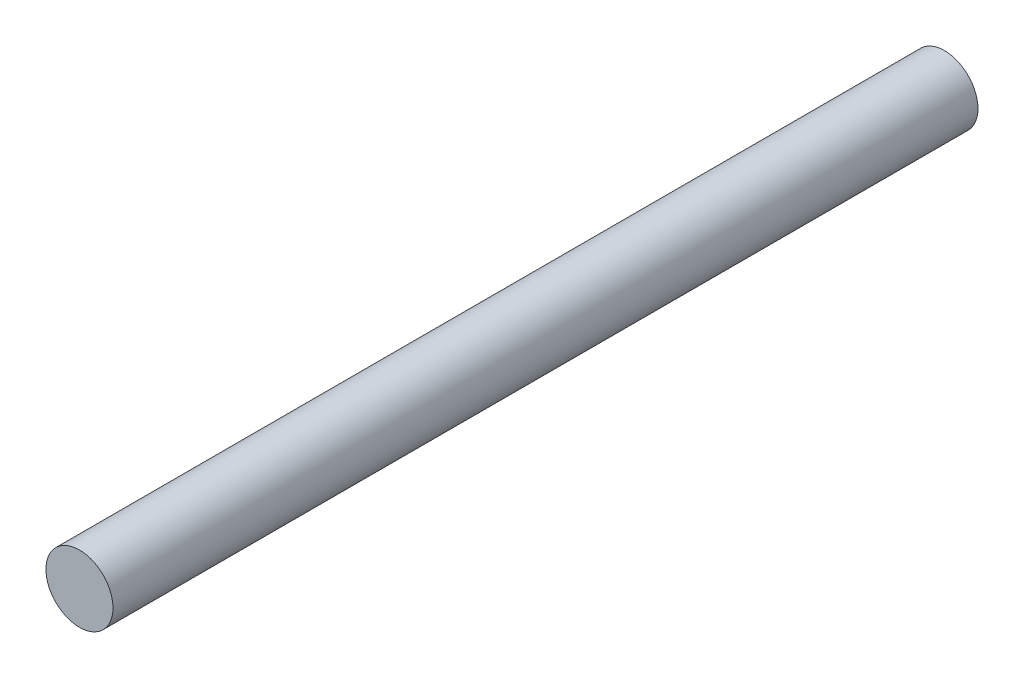
from build123d import *

# Parameters (mm, degrees)
SKETCH1_R           = 1
BOSS_EXTRUDE1_DEPTH = 25.8


with BuildPart() as part:
    # Sketch1 → Boss-Extrude1 (new body)
    with BuildSketch(Plane.XY):
        Circle(SKETCH1_R)
    extrude(amount=BOSS_EXTRUDE1_DEPTH)


solid = part.part
